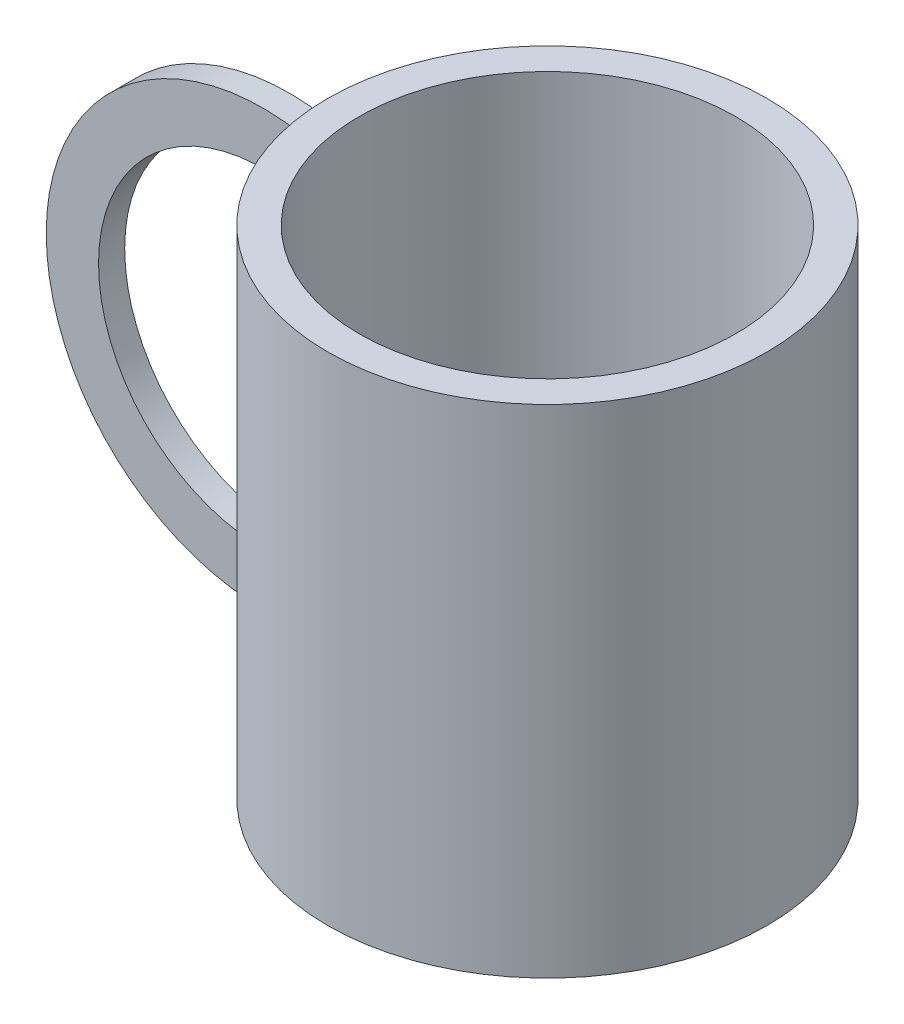
from build123d import *

# Parameters (mm, degrees)
CROQUIS1_R              = 42
CROQUIS1_R_2            = 36
SALIENTE_EXTRUIR1_DEPTH = 95
CROQUIS2_R              = 42
SALIENTE_EXTRUIR2_DEPTH = 5
EXTRUIR_L_MINA1_DEPTH   = 5


with BuildPart() as part:
    # Croquis1 → Saliente-Extruir1 (new body)
    with BuildSketch(Plane(origin=(0, 0, 0), x_dir=(1, 0, 0), z_dir=(0, 1, 0))):
        Circle(CROQUIS1_R)
        Circle(CROQUIS1_R_2, mode=Mode.SUBTRACT)
    extrude(amount=SALIENTE_EXTRUIR1_DEPTH)

    # Croquis2 → Saliente-Extruir2 (add)
    with BuildSketch(Plane.XZ):
        Circle(CROQUIS2_R)
    extrude(amount=-SALIENTE_EXTRUIR2_DEPTH)

    # Croquis3 → Extruir-Lámina1 (add)
    with BuildSketch(Plane.XY):
        with BuildLine():
            ThreePointArc((-42, 81.333269167), (-80.835192592, 50.726606051), (-42, 20.119942936))
            Line((-42, 20.119942936), (-39.662910525, 10.396876918))
            ThreePointArc((-39.662910525, 10.396876918), (-90.835192592, 50.726606051), (-39.662910525, 91.056335185))
            Line((-39.662910525, 91.056335185), (-42, 81.333269167))
        make_face()
    extrude(amount=EXTRUIR_L_MINA1_DEPTH)


solid = part.part
